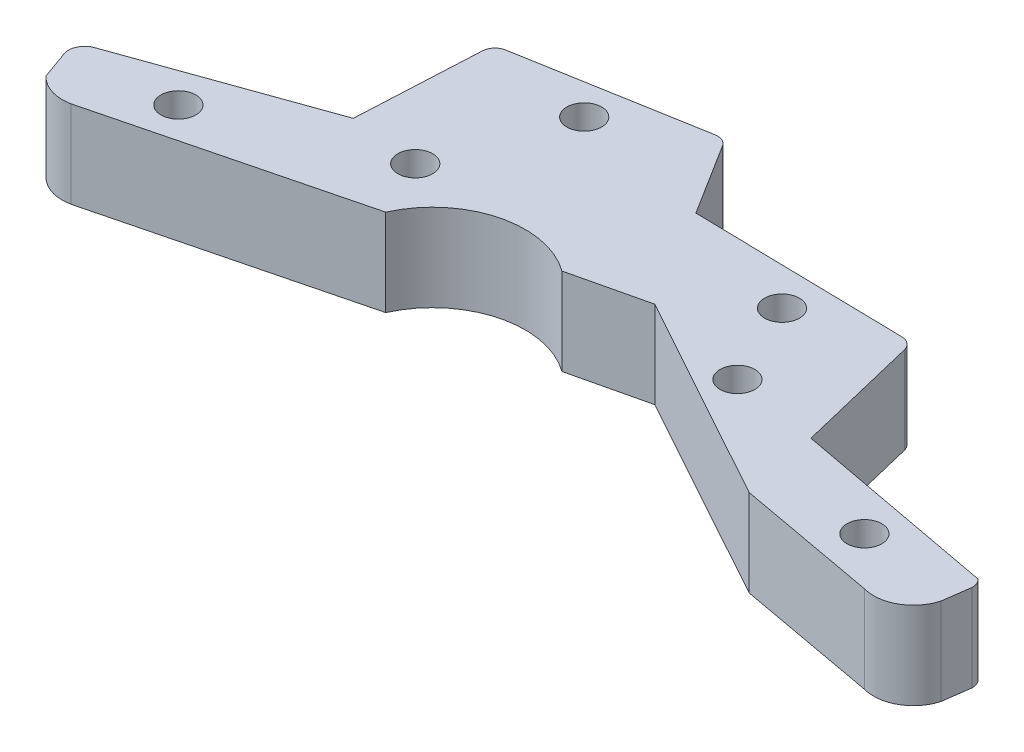
from build123d import *

# Parameters (mm, degrees)
SKETCH1_R           = 1
BOSS_EXTRUDE2_DEPTH = 5
FILLET1_R           = 0.75


with BuildPart() as part:
    # Sketch1 → Boss-Extrude2 (new body)
    with BuildSketch(Plane(origin=(0, 0, 0), x_dir=(1, 0, 0), z_dir=(0, 1, 0))):
        with BuildLine():
            Line((-1.136805092, 2.066410525), (-0.613869143, 0.60302827))
            ThreePointArc((-0.613869143, 0.60302827), (0.35214746, -0.005581798), (1.492263995, -0.066643898))
            Line((1.492263995, -0.066643898), (15.923799424, 3.58412039))
            ThreePointArc((15.923799424, 3.58412039), (19.413112634, 6.553816474), (23.917744363, 5.715547725))
            Line((23.917744363, 5.715547725), (28.235048802, 6.73364228))
            Line((28.235048802, 6.73364228), (40.313961493, 0.074349637))
            Line((40.313961493, 0.074349637), (48.41423182, -1.403905787))
            ThreePointArc((48.41423182, -1.403905787), (50.149589372, -1.191061521), (51.226168842, 0.186525195))
            Line((51.226168842, 0.186525195), (51.441108403, 1.760534064))
            ThreePointArc((51.441108403, 1.760534064), (51.382015555, 2.083995414), (51.185428041, 2.34757189))
            Line((51.185428041, 2.34757189), (39.388940164, 4.548224923))
            Line((39.388940164, 4.548224923), (37.817705686, 11.041835021))
            Line((37.817705686, 11.041835021), (37.66842193, 11.65879609))
            Line((37.66842193, 11.65879609), (37.488298502, 12.198995049))
            Line((37.488298502, 12.198995049), (37.342570627, 12.198995049))
            Line((37.342570627, 12.198995049), (24.882570627, 12.445855441))
            Line((24.882570627, 12.445855441), (22.035262293, 16.980664764))
            Line((22.035262293, 16.980664764), (10.708550227, 14.991797304))
            Line((10.708550227, 14.991797304), (10.323891999, 7.31840254))
            Line((10.323891999, 7.31840254), (-0.740858173, 3.364442041))
            ThreePointArc((-0.740858173, 3.364442041), (-1.207662762, 2.797429575), (-1.136805092, 2.066410525))
        make_face()
        with Locations((34.353341853, 5.361683953)):
            Circle(SKETCH1_R, mode=Mode.SUBTRACT)
        with Locations((45.677794697, 1.332114162)):
            Circle(SKETCH1_R, mode=Mode.SUBTRACT)
        with Locations((14.363757556, 6.840434301)):
            Circle(SKETCH1_R, mode=Mode.SUBTRACT)
        with Locations((32.086393371, 10.190351233)):
            Circle(SKETCH1_R, mode=Mode.SUBTRACT)
        with Locations((4.633423153, 2.960008936)):
            Circle(SKETCH1_R, mode=Mode.SUBTRACT)
        with Locations((16.892865834, 14.018563944)):
            Circle(SKETCH1_R, mode=Mode.SUBTRACT)
    extrude(amount=BOSS_EXTRUDE2_DEPTH)

    # Fillet1
    fillet1_edges = [part.edges().sort_by_distance(p)[0] for p in [
        (37.488298502, 2.5, -12.198995049),
        (22.035262293, 2.5, -16.980664764),
        (10.708550227, 2.5, -14.991797304),
    ]]
    fillet(fillet1_edges, radius=FILLET1_R)


solid = part.part
